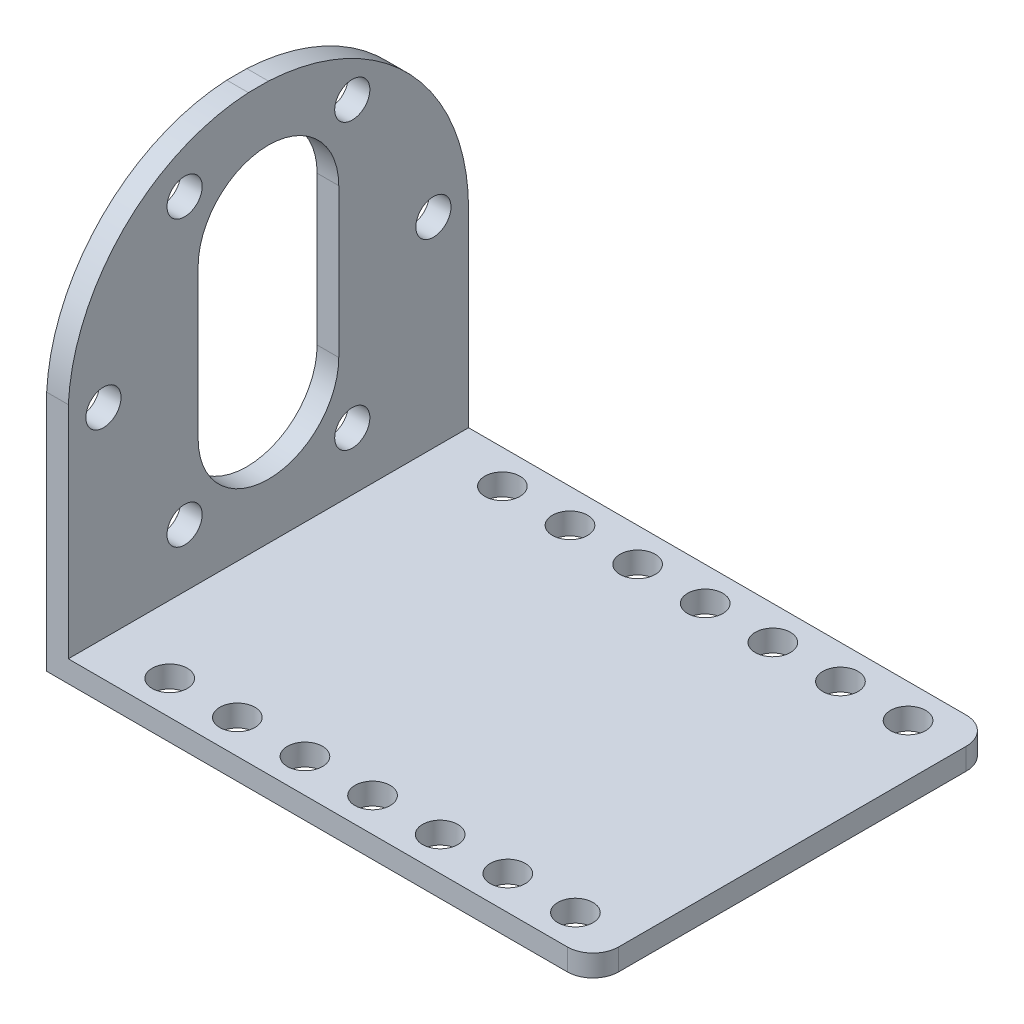
from build123d import *

# Parameters (mm, degrees)
BOSS_EXTRUDE1_DEPTH = 37.592
CUT_EXTRUDE1_DEPTH  = 37.592
SKETCH3_R           = 1.651
CUT_EXTRUDE3_DEPTH  = 37.592
CUT_EXTRUDE4_DEPTH  = 37.592
CUT_EXTRUDE5_DEPTH  = 37.592
SKETCH7_R           = 1.651
CUT_EXTRUDE6_DEPTH  = 37.592
LPATTERN1_COUNT     = 7
LPATTERN1_PITCH     = 6.35
CUT_EXTRUDE7_DEPTH  = 37.592


with BuildPart() as part:
    # Sketch1 → Boss-Extrude1 (new body)
    with BuildSketch(Plane.XY):
        Polygon((-1.016, 18.796), (1.016, 18.796), (1.016, -18.796), (50.292, -18.796), (50.292, -20.828), (-1.016, -20.828), (-1.016, -18.796), align=None)
    extrude(amount=-BOSS_EXTRUDE1_DEPTH)

    # Sketch2 → Cut-Extrude1 (cut)
    with BuildSketch(Plane.ZY.offset(1.016)):
        with BuildLine():
            Line((-25.4, -6.985), (-25.4, 6.985))
            ThreePointArc((-25.4, 6.985), (-18.796, 13.589), (-12.192, 6.985))
            Line((-12.192, 6.985), (-12.192, -6.985))
            ThreePointArc((-12.192, -6.985), (-18.796, -13.589), (-25.4, -6.985))
        make_face()
    extrude(amount=-CUT_EXTRUDE1_DEPTH, mode=Mode.SUBTRACT)

    # Sketch3 → Cut-Extrude3 (cut)
    with BuildSketch(Plane.ZY.offset(1.016)):
        with Locations((-34.29, 0)):
            Circle(SKETCH3_R)
        with Locations((-26.67, -13.344068345)):
            Circle(SKETCH3_R)
        with Locations((-10.922, -13.344068345)):
            Circle(SKETCH3_R)
        with Locations((-3.302, 0)):
            Circle(SKETCH3_R)
        with Locations((-10.922, 13.344068345)):
            Circle(SKETCH3_R)
        with Locations((-26.67, 13.344068345)):
            Circle(SKETCH3_R)
    extrude(amount=-CUT_EXTRUDE3_DEPTH, mode=Mode.SUBTRACT)

    # Sketch5 → Cut-Extrude4 (cut)
    with BuildSketch(Plane.ZY.offset(1.016)):
        with BuildLine():
            Line((-37.592, 18.796), (-37.592, -1.016))
            ThreePointArc((-37.592, -1.016), (-32.145348176, 12.638714937), (-18.796, 18.796))
            Line((-18.796, 18.796), (-37.592, 18.796))
        make_face()
        with BuildLine():
            Line((0, 18.796), (-16.915162607, 18.796))
            ThreePointArc((-16.915162607, 18.796), (-5.212279302, 13.583720698), (0, 1.880837393))
            Line((0, 1.880837393), (0, 18.796))
        make_face()
    extrude(amount=-CUT_EXTRUDE4_DEPTH, mode=Mode.SUBTRACT)

    # Sketch6 → Cut-Extrude5 (cut)
    with BuildSketch(Plane(origin=(0, -18.796, 0), x_dir=(1, 0, 0), z_dir=(0, 1, 0))):
        with BuildLine():
            Line((50.292, 2.413), (50.292, 0))
            Line((50.292, 0), (47.879, 0))
            ThreePointArc((47.879, 0), (49.585248663, 0.706751337), (50.292, 2.413))
        make_face()
    extrude(amount=-CUT_EXTRUDE5_DEPTH, mode=Mode.SUBTRACT)

    # Sketch7 → Cut-Extrude6 (cut)
    with BuildSketch(Plane(origin=(0, -18.796, 0), x_dir=(1, 0, 0), z_dir=(0, 1, 0))):
        with Locations((45.466, 3.175)):
            Circle(SKETCH7_R)
        with Locations((45.466, 34.417)):
            Circle(SKETCH7_R)
    cut_extrude6 = extrude(amount=-CUT_EXTRUDE6_DEPTH, mode=Mode.SUBTRACT)

    # LPattern1: Cut-Extrude6 ×7
    with Locations(*[(-i * LPATTERN1_PITCH, 0, 0) for i in range(1, LPATTERN1_COUNT)]):
        add(cut_extrude6, mode=Mode.SUBTRACT)

    # Sketch8 → Cut-Extrude7 (cut)
    with BuildSketch(Plane(origin=(0, -18.796, 0), x_dir=(1, 0, 0), z_dir=(0, 1, 0))):
        with BuildLine():
            Line((50.292, 35.052), (50.292, 37.592))
            Line((50.292, 37.592), (47.752, 37.592))
            ThreePointArc((47.752, 37.592), (49.548051224, 36.848051224), (50.292, 35.052))
        make_face()
    extrude(amount=-CUT_EXTRUDE7_DEPTH, mode=Mode.SUBTRACT)


solid = part.part
